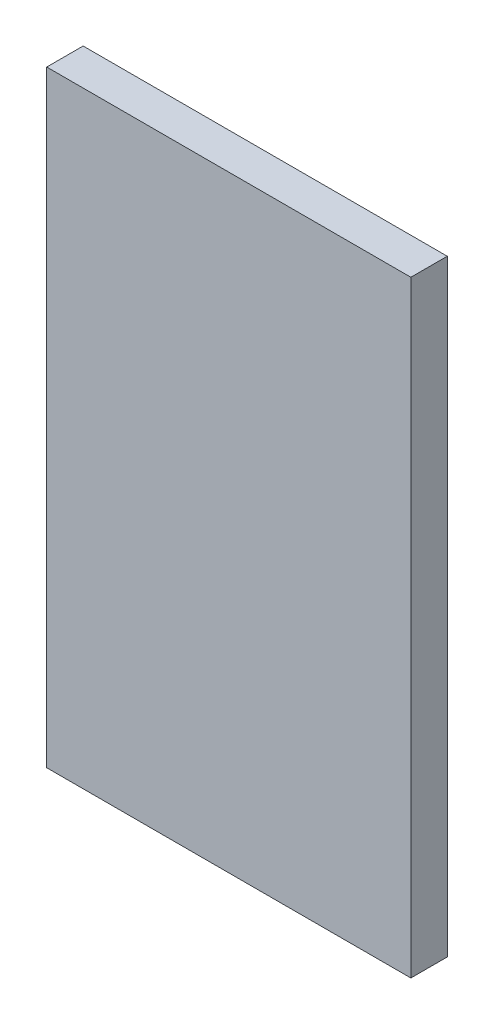
from build123d import *

# Parameters (mm, degrees)
ESQUISSE1_W        = 30
ESQUISSE1_H        = 50
BOSS_EXTRU_1_DEPTH = 3


with BuildPart() as part:
    # Esquisse1 → Boss.-Extru.1 (new body)
    with BuildSketch(Plane.XY):
        with Locations((-64.279447666, 18.970188902)):
            Rectangle(ESQUISSE1_W, ESQUISSE1_H)
    extrude(amount=BOSS_EXTRU_1_DEPTH)


solid = part.part
